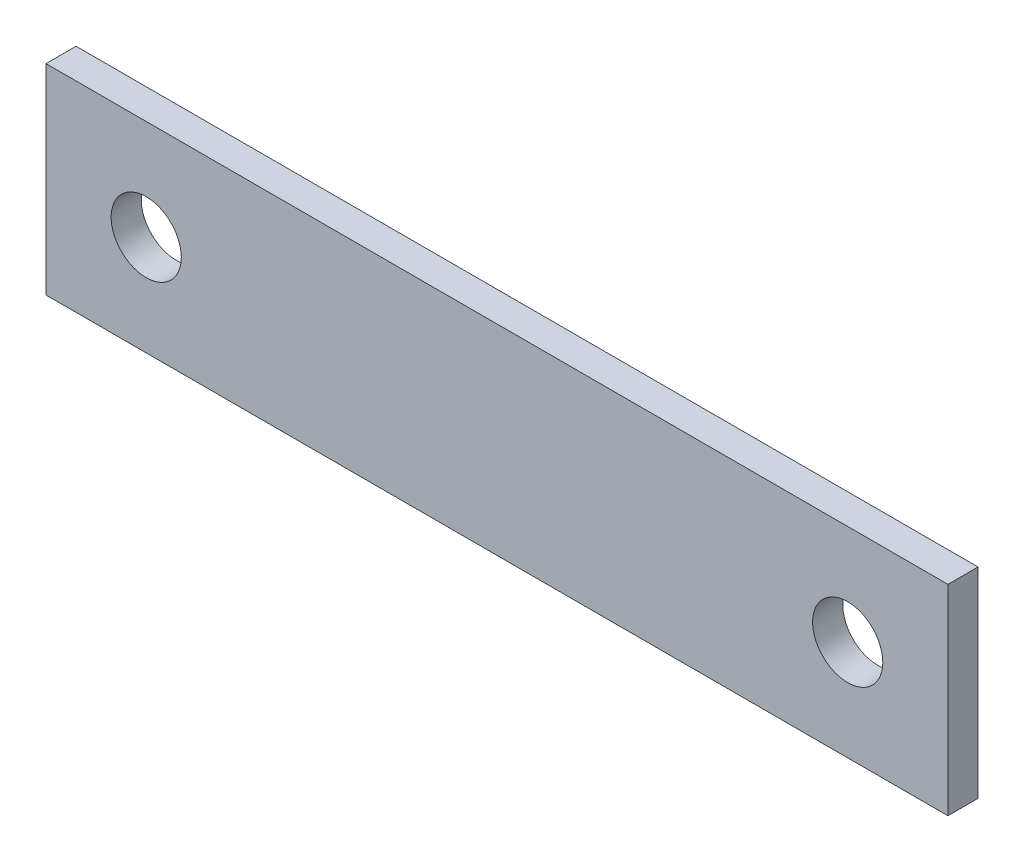
from build123d import *

# Parameters (mm, degrees)
CROQUIS1_W              = 90
CROQUIS1_H              = 20
CROQUIS1_R              = 3.5
SALIENTE_EXTRUIR1_DEPTH = 3


with BuildPart() as part:
    # Croquis1 → Saliente-Extruir1 (new body)
    with BuildSketch(Plane.XY):
        with Locations((-36.888493821, 16.005285962)):
            Rectangle(CROQUIS1_W, CROQUIS1_H)
        with Locations((-71.888493821, 16.005285962)):
            Circle(CROQUIS1_R, mode=Mode.SUBTRACT)
        with Locations((-1.888493821, 16.005285962)):
            Circle(CROQUIS1_R, mode=Mode.SUBTRACT)
    extrude(amount=SALIENTE_EXTRUIR1_DEPTH)


solid = part.part
